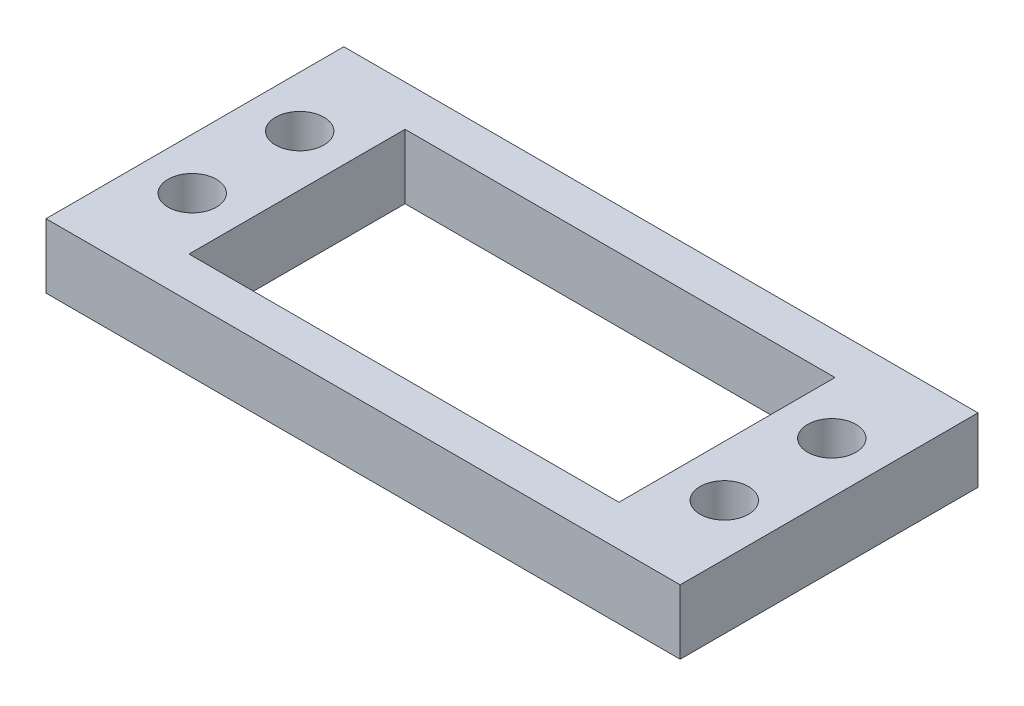
from build123d import *

# Parameters (mm, degrees)
SKETCH1_W           = 59
SKETCH1_H           = 27.707269776
SKETCH1_R           = 2.25
SKETCH1_W_2         = 40
SKETCH1_H_2         = 20.1
BOSS_EXTRUDE1_DEPTH = 6


with BuildPart() as part:
    # Sketch1 → Boss-Extrude1 (new body)
    with BuildSketch(Plane(origin=(0, 0, 0), x_dir=(1, 0, 0), z_dir=(0, 1, 0))):
        with Locations((29.5, 13.853634888)):
            Rectangle(SKETCH1_W, SKETCH1_H)
        with Locations((4.75, 18.853634888)):
            Circle(SKETCH1_R, mode=Mode.SUBTRACT)
        with Locations((4.75, 8.853634888)):
            Circle(SKETCH1_R, mode=Mode.SUBTRACT)
        with Locations((54.25, 8.853634888)):
            Circle(SKETCH1_R, mode=Mode.SUBTRACT)
        with Locations((54.25, 18.853634888)):
            Circle(SKETCH1_R, mode=Mode.SUBTRACT)
        with Locations((29.5, 13.853634888)):
            Rectangle(SKETCH1_W_2, SKETCH1_H_2, mode=Mode.SUBTRACT)
    extrude(amount=BOSS_EXTRUDE1_DEPTH)


solid = part.part
